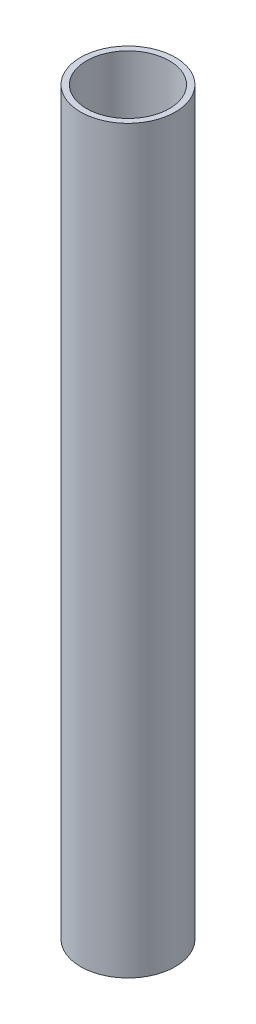
from build123d import *

# Parameters (mm, degrees)
SKETCH_1_R      = 8
SKETCH_1_R_2    = 7
EXTRUDE_1_DEPTH = 125


with BuildPart() as part:
    # 草图1 → 凸台-拉伸1 (new body)
    with BuildSketch(Plane(origin=(0, 0, 0), x_dir=(1, 0, 0), z_dir=(0, 1, 0))):
        Circle(SKETCH_1_R)
        Circle(SKETCH_1_R_2, mode=Mode.SUBTRACT)
    extrude(amount=EXTRUDE_1_DEPTH)


solid = part.part
